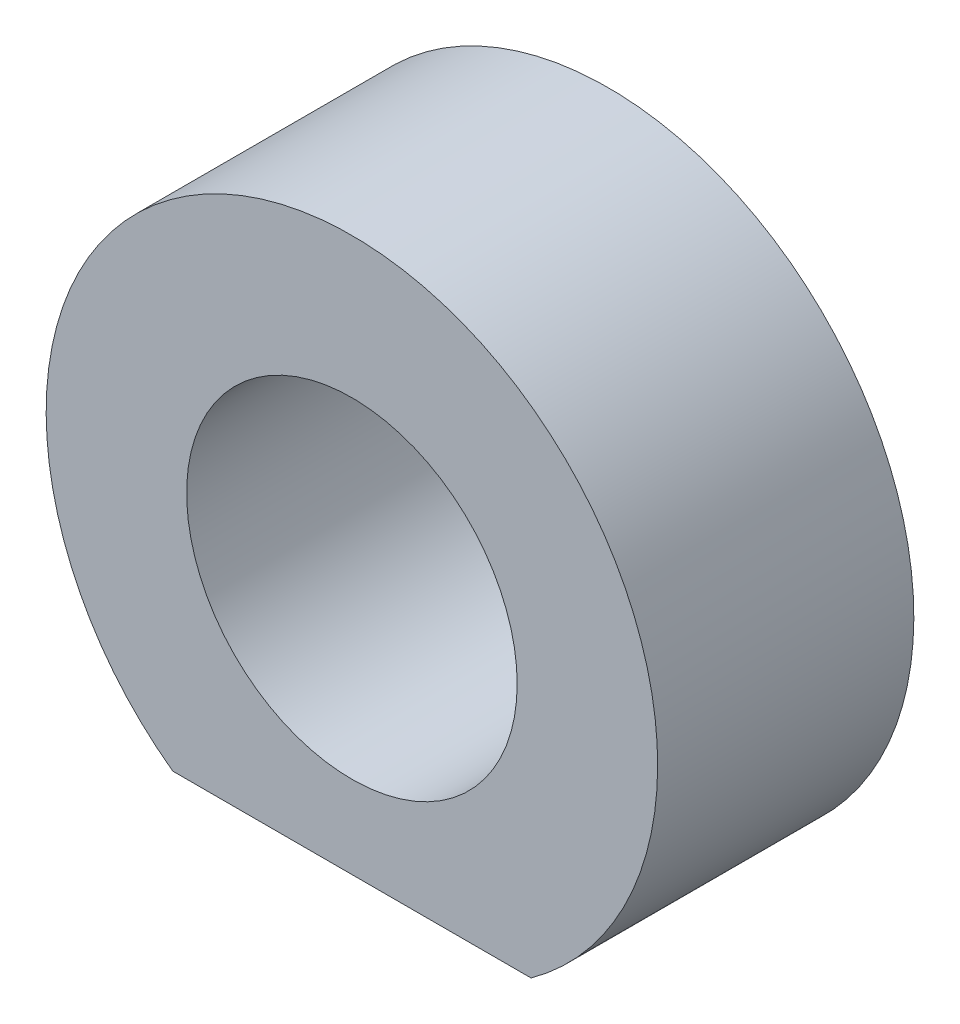
from build123d import *

# Parameters (mm, degrees)
SKETCH1_R                    = 10
BOSS_EXTRUDE1_DEPTH          = 15.5
F_2_0_2_DIAMETER_HOLE1_D     = 2
F_2_0_2_DIAMETER_HOLE1_DEPTH = 2
F_2_0_2_DIAMETER_HOLE1_TIP   = 0.600860619


with BuildPart() as part:
    # Sketch1 → Boss-Extrude1 (new body)
    with BuildSketch(Plane.XY):
        with BuildLine():
            Line((-10.84, -14.991477579), (10.84, -14.991477579))
            ThreePointArc((10.84, -14.991477579), (0, 18.5), (-10.84, -14.991477579))
        make_face()
        Circle(SKETCH1_R, mode=Mode.SUBTRACT)
    extrude(amount=BOSS_EXTRUDE1_DEPTH)

    # Ø2.0 (2) Diameter Hole1
    with Locations(Plane(origin=(0, -14.991477579, 0), x_dir=(-1, 0, 0), z_dir=(0, -1, 0))):
        with Locations((0, -7.75)):
            Hole(F_2_0_2_DIAMETER_HOLE1_D / 2, depth=F_2_0_2_DIAMETER_HOLE1_DEPTH)
            with Locations((0, 0, -(F_2_0_2_DIAMETER_HOLE1_DEPTH + F_2_0_2_DIAMETER_HOLE1_TIP / 2))):  # 118° drill point
                Cone(0, F_2_0_2_DIAMETER_HOLE1_D / 2, F_2_0_2_DIAMETER_HOLE1_TIP, mode=Mode.SUBTRACT)


solid = part.part
